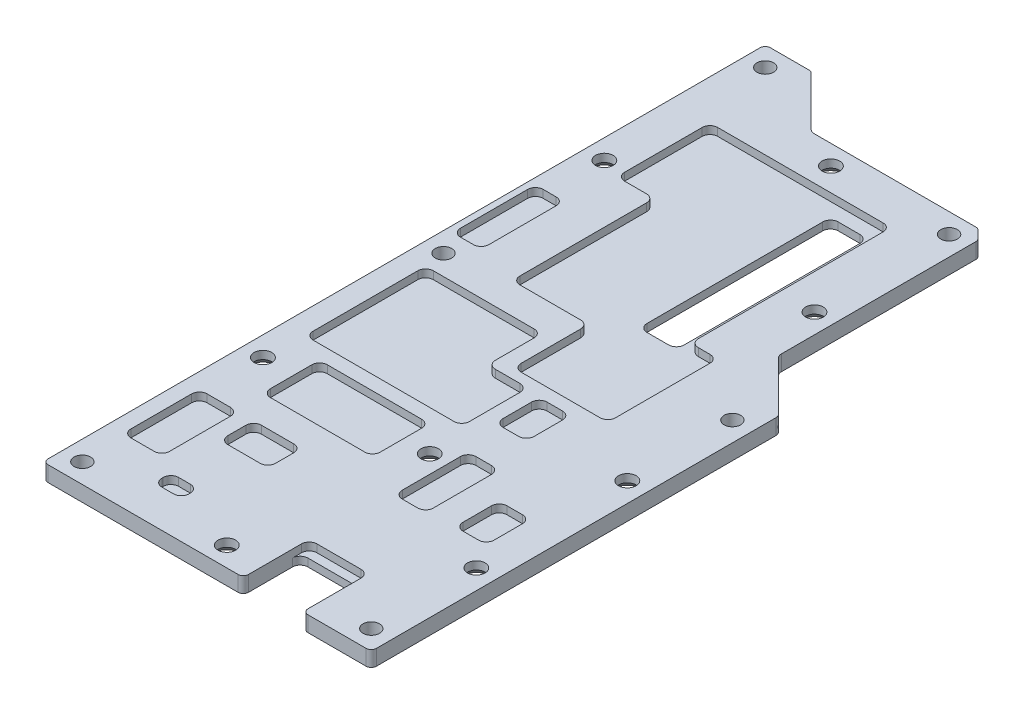
from build123d import *

# Parameters (mm, degrees)
BOSS_EXTRUDE1_DEPTH                          = 3
CUT_EXTRUDE1_DEPTH                           = 1.5
CUT_EXTRUDE2_REACH                           = 5
F_3_2_3_2_DIAMETER_HOLE1_D                   = 3.2
CSK_FOR_M3_COUNTERSUNK_RAISED_HEAD_S_2_COUNT = 2
CSK_FOR_M3_COUNTERSUNK_RAISED_HEAD_S_2_PITCH = 122.025787439
CSK_FOR_M3_COUNTERSUNK_RAISED_HEAD_S_3_COUNT = 2
CSK_FOR_M3_COUNTERSUNK_RAISED_HEAD_S_3_PITCH = 79.565271947
CSK_FOR_M3_COUNTERSUNK_RAISED_HEAD_S_4_COUNT = 2
CSK_FOR_M3_COUNTERSUNK_RAISED_HEAD_S_4_PITCH = 89.943536177
CSK_FOR_M3_COUNTERSUNK_RAISED_HEAD_S_5_COUNT = 2
CSK_FOR_M3_COUNTERSUNK_RAISED_HEAD_S_5_PITCH = 87.496400497
CSK_FOR_M3_COUNTERSUNK_RAISED_HEAD_S_6_COUNT = 2
CSK_FOR_M3_COUNTERSUNK_RAISED_HEAD_S_6_PITCH = 106.831083492
CSK_FOR_M3_COUNTERSUNK_RAISED_HEAD_S_7_COUNT = 2
CSK_FOR_M3_COUNTERSUNK_RAISED_HEAD_S_7_PITCH = 34.650558437
CSK_FOR_M3_COUNTERSUNK_RAISED_HEAD_S_8_COUNT = 2
CSK_FOR_M3_COUNTERSUNK_RAISED_HEAD_S_8_PITCH = 31.014532078


with BuildPart() as part:
    # Sketch1 → Boss-Extrude1 (new body)
    with BuildSketch(Plane(origin=(0, 0, 0), x_dir=(1, 0, 0), z_dir=(0, 1, 0))):
        with BuildLine():
            Line((0, 1), (0, 138.7))
            ThreePointArc((0, 138.7), (0.292893219, 139.407106781), (1, 139.7))
            Line((1, 139.7), (8.475786438, 139.7))
            ThreePointArc((8.475786438, 139.7), (8.85846987, 139.623879533), (9.182893219, 139.407106781))
            Line((9.182893219, 139.407106781), (18.610660172, 129.979339828))
            ThreePointArc((18.610660172, 129.979339828), (19.097295195, 129.654180701), (19.671320344, 129.54))
            Line((19.671320344, 129.54), (50.895786438, 129.54))
            ThreePointArc((50.895786438, 129.54), (51.27846987, 129.463879533), (51.602893219, 129.247106781))
            Line((51.602893219, 129.247106781), (53.047106781, 127.802893219))
            ThreePointArc((53.047106781, 127.802893219), (53.263879533, 127.47846987), (53.34, 127.095786438))
            Line((53.34, 127.095786438), (53.34, 89.521320344))
            ThreePointArc((53.34, 89.521320344), (53.454180701, 88.947295195), (53.779339828, 88.460660172))
            Line((53.779339828, 88.460660172), (63.207106781, 79.032893219))
            ThreePointArc((63.207106781, 79.032893219), (63.423879533, 78.70846987), (63.5, 78.325786438))
            Line((63.5, 78.325786438), (63.5, 1))
            ThreePointArc((63.5, 1), (63.207106781, 0.292893219), (62.5, 0))
            Line((62.5, 0), (51.25, 0))
            ThreePointArc((51.25, 0), (50.542893219, 0.292893219), (50.25, 1))
            Line((50.25, 1), (50.25, 9.5))
            ThreePointArc((50.25, 9.5), (49.810660172, 10.560660172), (48.75, 11))
            Line((48.75, 11), (40.25, 11))
            ThreePointArc((40.25, 11), (39.189339828, 10.560660172), (38.75, 9.5))
            Line((38.75, 9.5), (38.75, 1))
            ThreePointArc((38.75, 1), (38.457106781, 0.292893219), (37.75, 0))
            Line((37.75, 0), (1, 0))
            ThreePointArc((1, 0), (0.292893219, 0.292893219), (0, 1))
        make_face()
    extrude(amount=BOSS_EXTRUDE1_DEPTH)

    # Sketch2 → Cut-Extrude1 (cut)
    with BuildSketch(Plane(origin=(0, 3, 0), x_dir=(1, 0, 0), z_dir=(0, 1, 0))):
        with BuildLine():
            Line((50.25, 0), (50.25, 11.25))
            ThreePointArc((50.25, 11.25), (49.810660172, 12.310660172), (48.75, 12.75))
            Line((48.75, 12.75), (40.25, 12.75))
            ThreePointArc((40.25, 12.75), (39.189339828, 12.310660172), (38.75, 11.25))
            Line((38.75, 11.25), (38.75, 0))
            Line((38.75, 0), (50.25, 0))
        make_face()
        with BuildLine():
            Line((52.25, 37.5), (55.25, 37.5))
            ThreePointArc((55.25, 37.5), (56.310660172, 37.060660172), (56.75, 36))
            Line((56.75, 36), (56.75, 30.5))
            ThreePointArc((56.75, 30.5), (56.310660172, 29.439339828), (55.25, 29))
            Line((55.25, 29), (52.25, 29))
            ThreePointArc((52.25, 29), (51.189339828, 29.439339828), (50.75, 30.5))
            Line((50.75, 30.5), (50.75, 36))
            ThreePointArc((50.75, 36), (51.189339828, 37.060660172), (52.25, 37.5))
        make_face()
        with BuildLine():
            Line((41, 42.75), (44, 42.75))
            ThreePointArc((44, 42.75), (45.060660172, 42.310660172), (45.5, 41.25))
            Line((45.5, 41.25), (45.5, 30))
            ThreePointArc((45.5, 30), (45.060660172, 28.939339828), (44, 28.5))
            Line((44, 28.5), (41, 28.5))
            ThreePointArc((41, 28.5), (39.939339828, 28.939339828), (39.5, 30))
            Line((39.5, 30), (39.5, 41.25))
            ThreePointArc((39.5, 41.25), (39.939339828, 42.310660172), (41, 42.75))
        make_face()
        with BuildLine():
            Line((11.25, 43.75), (29.5, 43.75))
            ThreePointArc((29.5, 43.75), (30.560660172, 43.310660172), (31, 42.25))
            Line((31, 42.25), (31, 34.25))
            ThreePointArc((31, 34.25), (30.560660172, 33.189339828), (29.5, 32.75))
            Line((29.5, 32.75), (11.25, 32.75))
            ThreePointArc((11.25, 32.75), (10.189339828, 33.189339828), (9.75, 34.25))
            Line((9.75, 34.25), (9.75, 42.25))
            ThreePointArc((9.75, 42.25), (10.189339828, 43.310660172), (11.25, 43.75))
        make_face()
        with BuildLine():
            Line((18, 10.5), (15.75, 10.5))
            ThreePointArc((15.75, 10.5), (14.689339828, 10.060660172), (14.25, 9))
            Line((14.25, 9), (14.25, 8.75))
            ThreePointArc((14.25, 8.75), (14.689339828, 7.689339828), (15.75, 7.25))
            Line((15.75, 7.25), (18, 7.25))
            ThreePointArc((18, 7.25), (19.060660172, 7.689339828), (19.5, 8.75))
            Line((19.5, 8.75), (19.5, 9))
            ThreePointArc((19.5, 9), (19.060660172, 10.060660172), (18, 10.5))
        make_face()
        with BuildLine():
            Line((4.25, 68.25), (4.25, 48))
            ThreePointArc((4.25, 48), (4.689339828, 46.939339828), (5.75, 46.5))
            Line((5.75, 46.5), (33, 46.5))
            ThreePointArc((33, 46.5), (34.060660172, 46.939339828), (34.5, 48))
            Line((34.5, 48), (34.5, 57.75))
            ThreePointArc((34.5, 57.75), (34.060660172, 58.810660172), (33, 59.25))
            Line((33, 59.25), (28.25, 59.25))
            ThreePointArc((28.25, 59.25), (27.189339828, 59.689339828), (26.75, 60.75))
            Line((26.75, 60.75), (26.75, 68.25))
            ThreePointArc((26.75, 68.25), (26.310660172, 69.310660172), (25.25, 69.75))
            Line((25.25, 69.75), (5.75, 69.75))
            ThreePointArc((5.75, 69.75), (4.689339828, 69.310660172), (4.25, 68.25))
        make_face()
        with BuildLine():
            Line((4.5, 27.25), (9, 27.25))
            ThreePointArc((9, 27.25), (10.060660172, 26.810660172), (10.5, 25.75))
            Line((10.5, 25.75), (10.5, 14))
            ThreePointArc((10.5, 14), (10.060660172, 12.939339828), (9, 12.5))
            Line((9, 12.5), (4.5, 12.5))
            ThreePointArc((4.5, 12.5), (3.439339828, 12.939339828), (3, 14))
            Line((3, 14), (3, 25.75))
            ThreePointArc((3, 25.75), (3.439339828, 26.810660172), (4.5, 27.25))
        make_face()
        with BuildLine():
            Line((15, 27.25), (21.25, 27.25))
            ThreePointArc((21.25, 27.25), (22.310660172, 26.810660172), (22.75, 25.75))
            Line((22.75, 25.75), (22.75, 22.25))
            ThreePointArc((22.75, 22.25), (22.310660172, 21.189339828), (21.25, 20.75))
            Line((21.25, 20.75), (15, 20.75))
            ThreePointArc((15, 20.75), (13.939339828, 21.189339828), (13.5, 22.25))
            Line((13.5, 22.25), (13.5, 25.75))
            ThreePointArc((13.5, 25.75), (13.939339828, 26.810660172), (15, 27.25))
        make_face()
        with BuildLine():
            Line((31.25, 61.25), (46.5, 61.25))
            ThreePointArc((46.5, 61.25), (47.560660172, 61.689339828), (48, 62.75))
            Line((48, 62.75), (48, 81))
            ThreePointArc((48, 81), (47.560660172, 82.060660172), (46.5, 82.5))
            Line((46.5, 82.5), (44.25, 82.5))
            ThreePointArc((44.25, 82.5), (43.189339828, 82.939339828), (42.75, 84))
            Line((42.75, 84), (42.75, 119.75))
            ThreePointArc((42.75, 119.75), (42.310660172, 120.810660172), (41.25, 121.25))
            Line((41.25, 121.25), (9.25, 121.25))
            ThreePointArc((9.25, 121.25), (8.189339828, 120.810660172), (7.75, 119.75))
            Line((7.75, 119.75), (7.75, 104.75))
            ThreePointArc((7.75, 104.75), (8.189339828, 103.689339828), (9.25, 103.25))
            Line((9.25, 103.25), (13.5, 103.25))
            ThreePointArc((13.5, 103.25), (14.560660172, 102.810660172), (15, 101.75))
            Line((15, 101.75), (15, 77.25))
            ThreePointArc((15, 77.25), (15.439339828, 76.189339828), (16.5, 75.75))
            Line((16.5, 75.75), (28.25, 75.75))
            ThreePointArc((28.25, 75.75), (29.310660172, 75.310660172), (29.75, 74.25))
            Line((29.75, 74.25), (29.75, 62.75))
            ThreePointArc((29.75, 62.75), (30.189339828, 61.689339828), (31.25, 61.25))
        make_face()
        with BuildLine():
            Line((38.75, 58.75), (41.75, 58.75))
            ThreePointArc((41.75, 58.75), (42.810660172, 58.310660172), (43.25, 57.25))
            Line((43.25, 57.25), (43.25, 51.75))
            ThreePointArc((43.25, 51.75), (42.810660172, 50.689339828), (41.75, 50.25))
            Line((41.75, 50.25), (38.75, 50.25))
            ThreePointArc((38.75, 50.25), (37.689339828, 50.689339828), (37.25, 51.75))
            Line((37.25, 51.75), (37.25, 57.25))
            ThreePointArc((37.25, 57.25), (37.689339828, 58.310660172), (38.75, 58.75))
        make_face()
        with BuildLine():
            Line((2.75, 94), (5.25, 94))
            ThreePointArc((5.25, 94), (6.310660172, 93.560660172), (6.75, 92.5))
            Line((6.75, 92.5), (6.75, 79.5))
            ThreePointArc((6.75, 79.5), (6.310660172, 78.439339828), (5.25, 78))
            Line((5.25, 78), (2.75, 78))
            ThreePointArc((2.75, 78), (1.689339828, 78.439339828), (1.25, 79.5))
            Line((1.25, 79.5), (1.25, 92.5))
            ThreePointArc((1.25, 92.5), (1.689339828, 93.560660172), (2.75, 94))
        make_face()
    extrude(amount=-CUT_EXTRUDE1_DEPTH, mode=Mode.SUBTRACT)

    # Sketch3 → Cut-Extrude2 (cut, up to next)
    with BuildSketch(Plane(origin=(0, 0, 0), x_dir=(-1, 0, 0), z_dir=(0, -1, 0)), mode=Mode.PRIVATE) as cut_extrude2_sk1:
        with BuildLine():
            Line((-39.44, 118.58), (-35.24, 118.58))
            ThreePointArc((-35.24, 118.58), (-34.179339828, 118.140660172), (-33.74, 117.08))
            Line((-33.74, 117.08), (-33.74, 83.08))
            ThreePointArc((-33.74, 83.08), (-34.179339828, 82.019339828), (-35.24, 81.58))
            Line((-35.24, 81.58), (-39.44, 81.58))
            ThreePointArc((-39.44, 81.58), (-40.500660172, 82.019339828), (-40.94, 83.08))
            Line((-40.94, 83.08), (-40.94, 117.08))
            ThreePointArc((-40.94, 117.08), (-40.500660172, 118.140660172), (-39.44, 118.58))
        make_face()
    cut_extrude2_tool1 = extrude(cut_extrude2_sk1.sketch, amount=-CUT_EXTRUDE2_REACH, mode=Mode.PRIVATE) & part.part
    add(cut_extrude2_tool1.solids().sort_by_distance((37.34, 0, -100.08))[0], mode=Mode.SUBTRACT)

    # Ø3.2 (3.2) Diameter Hole1 (through all)
    with Locations(Plane(origin=(0, 3, 0), x_dir=(1, 0, 0), z_dir=(0, 1, 0))):
        with Locations((3.81, 135.89), (49.53, 125.73), (59.69, 73.66), (59.69, 3.81), (3.81, 3.81), (3.81, 73.66)):
            Hole(F_3_2_3_2_DIAMETER_HOLE1_D / 2)

    # Sketch8 → CSK for M3 Countersunk Raised Head Screw1 (revolve, cut)
    with BuildSketch(Plane(origin=(26.67, 0, -125.73), x_dir=(0, 0, -1), z_dir=(1, 0, 0))):
        Polygon((0, 0), (0, 3), (1.7, 3), (1.7, 1.45), (3.15, 0), align=None)
    csk_for_m3_countersunk_raised_head_screw = revolve(axis=Axis((26.67, -6.35, -125.73), (0, 1, 0)), mode=Mode.SUBTRACT)

    # CSK for M3 Countersunk Raised Head S 2: CSK for M3 Countersunk Raised Head Screw1 ×2
    with Locations(*[Vector(0.041630545, 0, 0.999133073) * (i * CSK_FOR_M3_COUNTERSUNK_RAISED_HEAD_S_2_PITCH) for i in range(1, CSK_FOR_M3_COUNTERSUNK_RAISED_HEAD_S_2_COUNT)]):
        add(csk_for_m3_countersunk_raised_head_screw, mode=Mode.SUBTRACT)

    # CSK for M3 Countersunk Raised Head S 3: CSK for M3 Countersunk Raised Head Screw1 ×2
    with Locations(*[Vector(0.41500518, 0, 0.909819048) * (i * CSK_FOR_M3_COUNTERSUNK_RAISED_HEAD_S_3_PITCH) for i in range(1, CSK_FOR_M3_COUNTERSUNK_RAISED_HEAD_S_3_COUNT)]):
        add(csk_for_m3_countersunk_raised_head_screw, mode=Mode.SUBTRACT)

    # CSK for M3 Countersunk Raised Head S 4: CSK for M3 Countersunk Raised Head Screw1 ×2
    with Locations(*[Vector(-0.254159453, 0, 0.96716233) * (i * CSK_FOR_M3_COUNTERSUNK_RAISED_HEAD_S_4_PITCH) for i in range(1, CSK_FOR_M3_COUNTERSUNK_RAISED_HEAD_S_4_COUNT)]):
        add(csk_for_m3_countersunk_raised_head_screw, mode=Mode.SUBTRACT)

    # CSK for M3 Countersunk Raised Head S 5: CSK for M3 Countersunk Raised Head Screw1 ×2
    with Locations(*[Vector(0.107432991, 0, 0.994212328) * (i * CSK_FOR_M3_COUNTERSUNK_RAISED_HEAD_S_5_PITCH) for i in range(1, CSK_FOR_M3_COUNTERSUNK_RAISED_HEAD_S_5_COUNT)]):
        add(csk_for_m3_countersunk_raised_head_screw, mode=Mode.SUBTRACT)

    # CSK for M3 Countersunk Raised Head S 6: CSK for M3 Countersunk Raised Head Screw1 ×2
    with Locations(*[Vector(0.309086072, 0, 0.951034069) * (i * CSK_FOR_M3_COUNTERSUNK_RAISED_HEAD_S_6_PITCH) for i in range(1, CSK_FOR_M3_COUNTERSUNK_RAISED_HEAD_S_6_COUNT)]):
        add(csk_for_m3_countersunk_raised_head_screw, mode=Mode.SUBTRACT)

    # CSK for M3 Countersunk Raised Head S 7: CSK for M3 Countersunk Raised Head Screw1 ×2
    with Locations(*[Vector(0.659729627, 0, 0.75150304) * (i * CSK_FOR_M3_COUNTERSUNK_RAISED_HEAD_S_7_PITCH) for i in range(1, CSK_FOR_M3_COUNTERSUNK_RAISED_HEAD_S_7_COUNT)]):
        add(csk_for_m3_countersunk_raised_head_screw, mode=Mode.SUBTRACT)

    # CSK for M3 Countersunk Raised Head S 8: CSK for M3 Countersunk Raised Head Screw1 ×2
    with Locations(*[Vector(-0.737073832, 0, 0.675812227) * (i * CSK_FOR_M3_COUNTERSUNK_RAISED_HEAD_S_8_PITCH) for i in range(1, CSK_FOR_M3_COUNTERSUNK_RAISED_HEAD_S_8_COUNT)]):
        add(csk_for_m3_countersunk_raised_head_screw, mode=Mode.SUBTRACT)


solid = part.part
